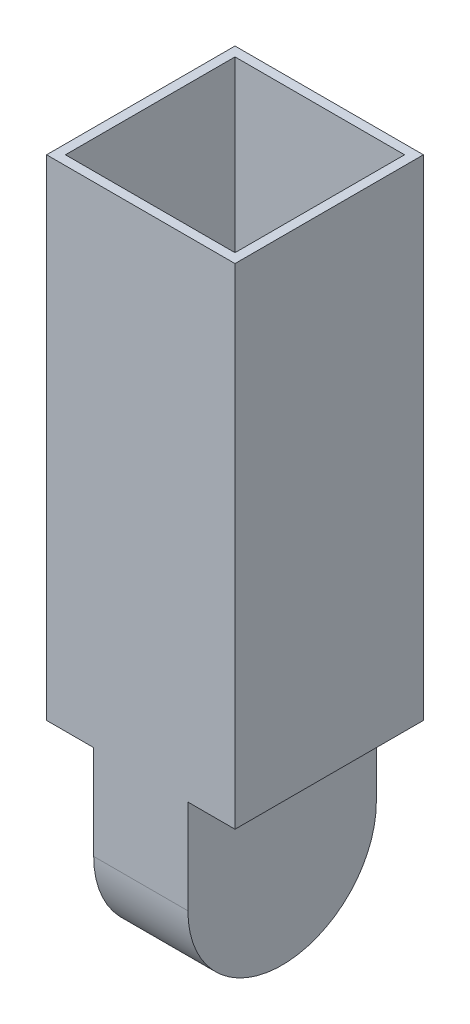
from build123d import *

# Parameters (mm, degrees)
SKETCH_1_W      = 20
SKETCH_1_H      = 20
SKETCH_1_W_2    = 18
SKETCH_1_H_2    = 18
EXTRUDE_1_DEPTH = 50
SKETCH_2_W      = 20
SKETCH_2_H      = 20
EXTRUDE_2_DEPTH = 2
EXTRUDE_3_DEPTH = 5


with BuildPart() as part:
    # 草图1 → 凸台-拉伸1 (new body)
    with BuildSketch(Plane(origin=(0, 0, 0), x_dir=(1, 0, 0), z_dir=(0, 1, 0))):
        Rectangle(SKETCH_1_W, SKETCH_1_H)
        Rectangle(SKETCH_1_W_2, SKETCH_1_H_2, mode=Mode.SUBTRACT)
    extrude(amount=EXTRUDE_1_DEPTH)

    # 草图2 → 凸台-拉伸2 (add)
    with BuildSketch(Plane.XZ):
        Rectangle(SKETCH_2_W, SKETCH_2_H)
    extrude(amount=EXTRUDE_2_DEPTH)

    # 草图6 → 凸台-拉伸3 (add, symmetric)
    with BuildSketch(Plane(origin=(0, 0, 0), x_dir=(0, 0, -1), z_dir=(1, 0, 0))):
        with BuildLine():
            Line((-10, -2), (10, -2))
            Line((10, -2), (10, -12))
            ThreePointArc((10, -12), (0, -22), (-10, -12))
            Line((-10, -12), (-10, -2))
        make_face()
    extrude(amount=EXTRUDE_3_DEPTH, both=True)


solid = part.part
